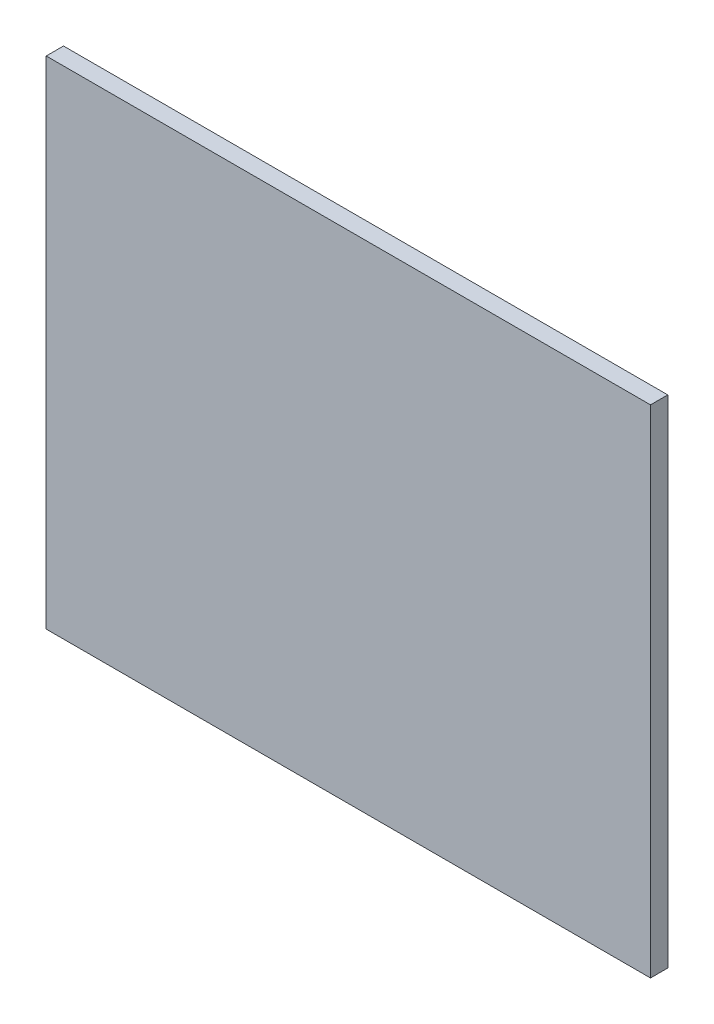
from build123d import *

# Parameters (mm, degrees)
SKETCH_1_W      = 140
SKETCH_1_H      = 115
EXTRUDE_1_DEPTH = 4


with BuildPart() as part:
    # 草图1 → 凸台-拉伸1 (new body)
    with BuildSketch(Plane.XY):
        with Locations((6.416065911, -11.434088568)):
            Rectangle(SKETCH_1_W, SKETCH_1_H)
    extrude(amount=EXTRUDE_1_DEPTH)


solid = part.part
